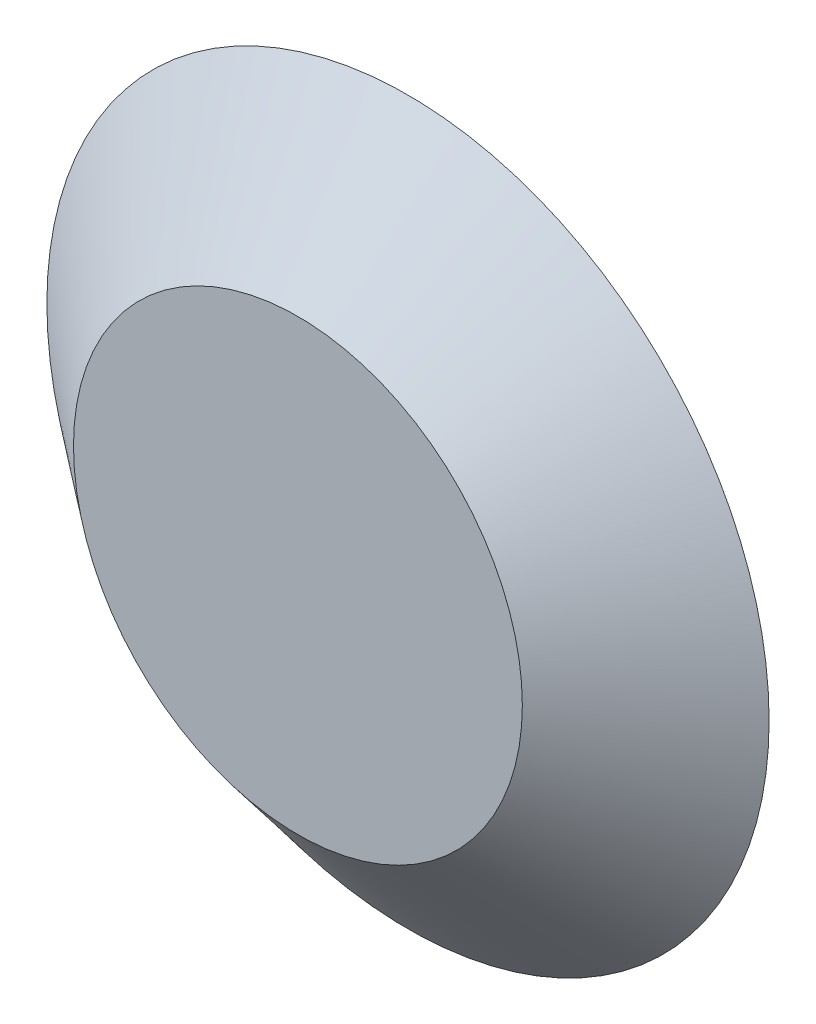
from build123d import *

# Parameters (mm, degrees)
SKETCH1_R           = 133.5
BOSS_EXTRUDE1_DEPTH = 40.7
BOSS_EXTRUDE1_TAPER = 51.15


with BuildPart() as part:
    # Sketch1 → Boss-Extrude1 (new body)
    with BuildSketch(Plane.XY):
        Circle(SKETCH1_R)
    extrude(amount=BOSS_EXTRUDE1_DEPTH, taper=BOSS_EXTRUDE1_TAPER)


solid = part.part
